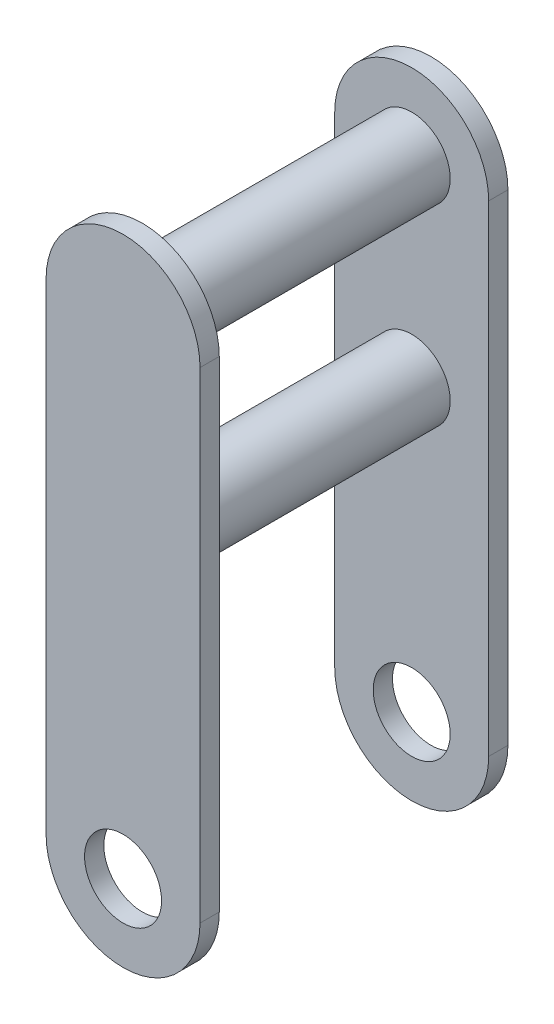
from build123d import *

# Parameters (mm, degrees)
BOSS_EXTRUDE1_START = 75
SKETCH1_R           = 20
BOSS_EXTRUDE1_DEPTH = 5
SKETCH2_R           = 20
BOSS_EXTRUDE2_DEPTH = 140


with BuildPart() as part:
    # Sketch1 → Boss-Extrude1 (new body, symmetric)
    with BuildSketch(Plane.XY.offset(BOSS_EXTRUDE1_START)):
        with BuildLine():
            Line((-40, 0), (-40, 250))
            ThreePointArc((-40, 250), (0, 290), (40, 250))
            Line((40, 250), (40, 0))
            ThreePointArc((40, 0), (0, -40), (-40, 0))
        make_face()
        Circle(SKETCH1_R, mode=Mode.SUBTRACT)
    boss_extrude1 = extrude(amount=BOSS_EXTRUDE1_DEPTH, both=True)

    # Sketch2 → Boss-Extrude2 (add)
    with BuildSketch(Plane(origin=(0, 0, 70), x_dir=(-1, 0, 0), z_dir=(0, 0, -1))):
        with Locations((0, 250)):
            Circle(SKETCH2_R)
        with Locations((0, 150)):
            Circle(SKETCH2_R)
    extrude(amount=BOSS_EXTRUDE2_DEPTH)

    # Mirror2: Boss-Extrude1 across plane
    add(boss_extrude1.mirror(Plane.XY))


solid = part.part
